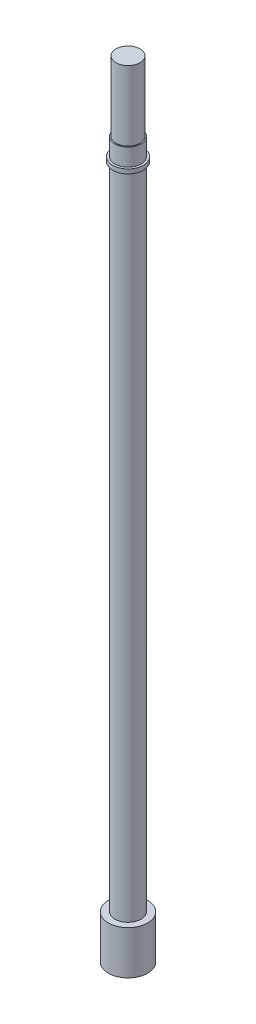
from build123d import *

# Parameters (mm, degrees)
SKETCH2_R           = 3
BOSS_EXTRUDE1_DEPTH = 170
SKETCH3_R           = 4.5
BOSS_EXTRUDE2_DEPTH = 10
SKETCH4_OUTSIDE_W   = 47.09
SKETCH4_OUTSIDE_H   = 47.09
SKETCH4_OUTSIDE_R   = 2.75
CUT_EXTRUDE1_DEPTH  = 16
BOSS_EXTRUDE3_START = -21
SKETCH5_R           = 3.5
BOSS_EXTRUDE3_DEPTH = 1


with BuildPart() as part:
    # Sketch2 → Boss-Extrude1 (new body)
    with BuildSketch(Plane(origin=(0, 0, 0), x_dir=(1, 0, 0), z_dir=(0, 1, 0))):
        with Locations(Location((0, 0, 0), (0, 0, 270))):  # turned: the seam where the file's is
            Circle(SKETCH2_R)
    extrude(amount=BOSS_EXTRUDE1_DEPTH)

    # Sketch3 → Boss-Extrude2 (add)
    with BuildSketch(Plane.XZ):
        with Locations(Location((0, 0, 0), (0, 0, 270))):  # turned: the seam where the file's is
            Circle(SKETCH3_R)
    extrude(amount=BOSS_EXTRUDE2_DEPTH)

    # Sketch4 outside → Cut-Extrude1 (cut)
    with BuildSketch(Plane(origin=(0, 170, 0), x_dir=(1, 0, 0), z_dir=(0, 1, 0))):
        Rectangle(SKETCH4_OUTSIDE_W, SKETCH4_OUTSIDE_H)
        with Locations(Location((0, 0, 0), (0, 0, 270))):  # turned: the seam where the file's is
            Circle(SKETCH4_OUTSIDE_R, mode=Mode.SUBTRACT)
    extrude(amount=-CUT_EXTRUDE1_DEPTH, mode=Mode.SUBTRACT)

    # Sketch5 → Boss-Extrude3 (add)
    with BuildSketch(Plane(origin=(0, 170, 0), x_dir=(1, 0, 0), z_dir=(0, 1, 0)).offset(BOSS_EXTRUDE3_START)):
        with Locations(Location((0, 0, 0), (0, 0, 270))):  # turned: the seam where the file's is
            Circle(SKETCH5_R)
    extrude(amount=BOSS_EXTRUDE3_DEPTH)


solid = part.part
